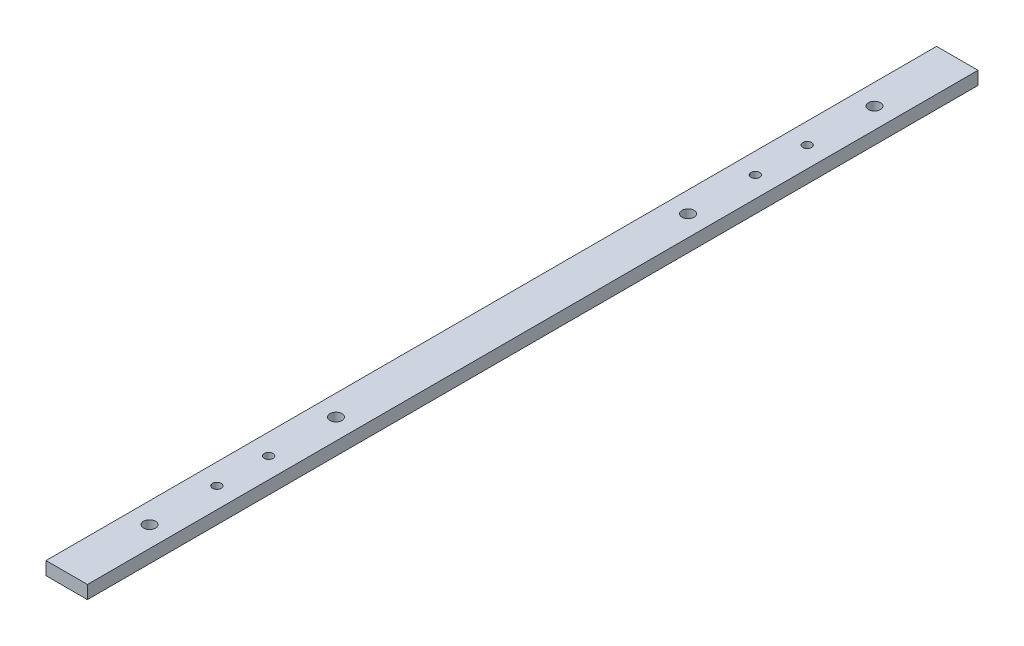
from build123d import *

# Parameters (mm, degrees)
SKETCH1_W             = 20
SKETCH1_H             = 430
BOSS_EXTRUDE1_DEPTH   = 6.35
M5_CLEARANCE_HOLE1_D  = 5.8
M5X0_8_TAPPED_HOLE1_D = 4.2


with BuildPart() as part:
    # Sketch1 → Boss-Extrude1 (new body)
    with BuildSketch(Plane(origin=(0, 0, 0), x_dir=(1, 0, 0), z_dir=(0, 1, 0))):
        Rectangle(SKETCH1_W, SKETCH1_H)
    extrude(amount=BOSS_EXTRUDE1_DEPTH)

    # M5 Clearance Hole1 (through all)
    with Locations(Plane(origin=(0, 6.35, 0), x_dir=(1, 0, 0), z_dir=(0, 1, 0))):
        with Locations((0, -175), (0, -85)):
            m5_clearance_hole1 = Hole(M5_CLEARANCE_HOLE1_D / 2)

    # Mirror1: M5 Clearance Hole1 across plane
    add(m5_clearance_hole1.mirror(Plane.XY), mode=Mode.SUBTRACT)

    # M5x0.8 Tapped Hole1 (through all)
    with Locations(Plane(origin=(0, 6.35, 0), x_dir=(1, 0, 0), z_dir=(0, 1, 0))):
        with Locations((0, -142.5), (0, -117.5)):
            m5x0_8_tapped_hole1 = Hole(M5X0_8_TAPPED_HOLE1_D / 2)

    # Mirror2: M5x0.8 Tapped Hole1 across plane
    add(m5x0_8_tapped_hole1.mirror(Plane.XY), mode=Mode.SUBTRACT)


solid = part.part
